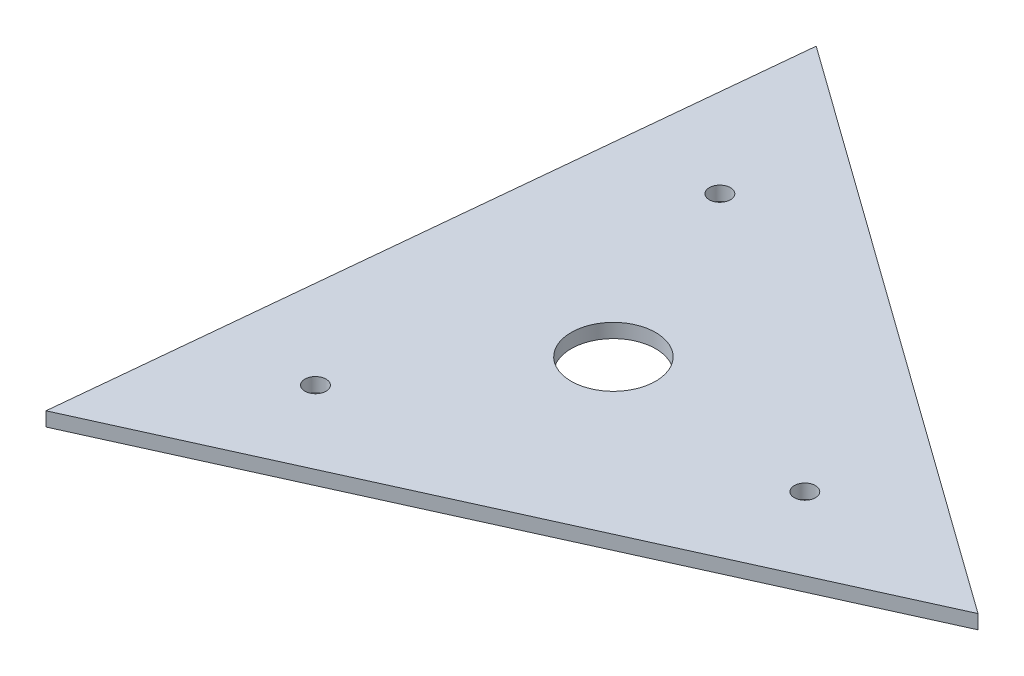
from build123d import *

# Parameters (mm, degrees)
SKETCH1_R           = 7.5
SKETCH1_R_2         = 30
BOSS_EXTRUDE1_DEPTH = 10


with BuildPart() as part:
    # Sketch1 → Boss-Extrude1 (new body)
    with BuildSketch(Plane(origin=(0, 0, 0), x_dir=(1, 0, 0), z_dir=(0, 1, 0))):
        Polygon((287.272653599, -28.421045507), (-119.022979389, 262.995938582), (-168.24967421, -234.574893076), align=None)
        with Locations((-62.5, 138.101451046)):
            Circle(SKETCH1_R, mode=Mode.SUBTRACT)
        with Locations((150.849364905, -14.924137787)):
            Circle(SKETCH1_R, mode=Mode.SUBTRACT)
        with Locations((-88.349364905, -123.17731326)):
            Circle(SKETCH1_R, mode=Mode.SUBTRACT)
        Circle(SKETCH1_R_2, mode=Mode.SUBTRACT)
    extrude(amount=BOSS_EXTRUDE1_DEPTH)


solid = part.part
